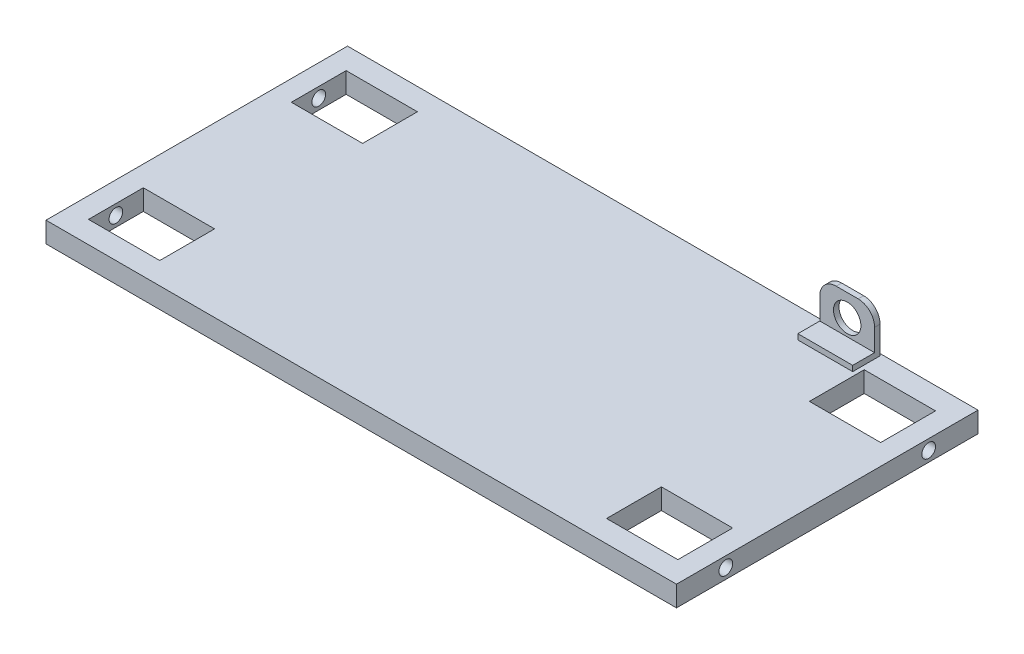
from build123d import *

# Parameters (mm, degrees)
SKETCH1_W           = 292.1
SKETCH1_H           = 139.7
BOSS_EXTRUDE1_DEPTH = 9.525
SKETCH2_W           = 33.02
SKETCH2_H           = 25.4
CUT_EXTRUDE1_DEPTH  = 9.525
SKETCH3_R           = 3.175
CUT_EXTRUDE2_DEPTH  = 9.525
SKETCH4_W           = 25.4
SKETCH4_H           = 12.7
BOSS_EXTRUDE2_DEPTH = 20.32
SKETCH5_W           = 25.4
SKETCH5_H           = 10.16
CUT_EXTRUDE3_DEPTH  = 17.78
FILLET2_R           = 7.62
SKETCH6_R           = 6.35
CUT_EXTRUDE4_DEPTH  = 2.54


with BuildPart() as part:
    # Sketch1 → Boss-Extrude1 (new body)
    with BuildSketch(Plane(origin=(0, 0, 0), x_dir=(1, 0, 0), z_dir=(0, 1, 0))):
        Rectangle(SKETCH1_W, SKETCH1_H)
    extrude(amount=BOSS_EXTRUDE1_DEPTH)

    # Sketch2 → Cut-Extrude1 (cut)
    with BuildSketch(Plane(origin=(0, 9.525, 0), x_dir=(1, 0, 0), z_dir=(0, 1, 0))):
        with Locations((-120.015, 46.99)):
            Rectangle(SKETCH2_W, SKETCH2_H)
        with Locations((-120.015, -46.99)):
            Rectangle(SKETCH2_W, SKETCH2_H)
        with Locations((120.015, 46.99)):
            Rectangle(SKETCH2_W, SKETCH2_H)
        with Locations((120.015, -46.99)):
            Rectangle(SKETCH2_W, SKETCH2_H)
    extrude(amount=-CUT_EXTRUDE1_DEPTH, mode=Mode.SUBTRACT)

    # Sketch3 → Cut-Extrude2 (cut)
    with BuildSketch(Plane(origin=(146.05, 0, 0), x_dir=(0, 0, -1), z_dir=(1, 0, 0))):
        with Locations((-46.99, 4.7625)):
            Circle(SKETCH3_R)
        with Locations((46.99, 4.7625)):
            Circle(SKETCH3_R)
    cut_extrude2 = extrude(amount=-CUT_EXTRUDE2_DEPTH, mode=Mode.SUBTRACT)

    # Mirror1: Cut-Extrude2 across plane
    add(cut_extrude2.mirror(Plane(origin=(0, 0, 0), x_dir=(0, 0, 1), z_dir=(1, 0, 0))), mode=Mode.SUBTRACT)

    # Sketch4 → Boss-Extrude2 (add)
    with BuildSketch(Plane(origin=(0, 9.525, 0), x_dir=(1, 0, 0), z_dir=(0, 1, 0))):
        with Locations((88.9, 62.590737259)):
            Rectangle(SKETCH4_W, SKETCH4_H)
    extrude(amount=BOSS_EXTRUDE2_DEPTH)

    # Sketch5 → Cut-Extrude3 (cut)
    with BuildSketch(Plane(origin=(0, 29.845, 0), x_dir=(1, 0, 0), z_dir=(0, 1, 0))):
        with Locations((88.9, 61.320737259)):
            Rectangle(SKETCH5_W, SKETCH5_H)
    extrude(amount=-CUT_EXTRUDE3_DEPTH, mode=Mode.SUBTRACT)

    # Fillet2
    fillet2_edges = [part.edges().sort_by_distance(p)[0] for p in [
        (101.6, 29.845, -67.670737259),
        (76.2, 29.845, -67.670737259),
    ]]
    fillet(fillet2_edges, radius=FILLET2_R)

    # Sketch6 → Cut-Extrude4 (cut)
    with BuildSketch(Plane(origin=(0, 0, -68.940737259), x_dir=(-1, 0, 0), z_dir=(0, 0, -1))):
        with Locations((-88.9, 19.685)):
            Circle(SKETCH6_R)
    extrude(amount=-CUT_EXTRUDE4_DEPTH, mode=Mode.SUBTRACT)


solid = part.part
